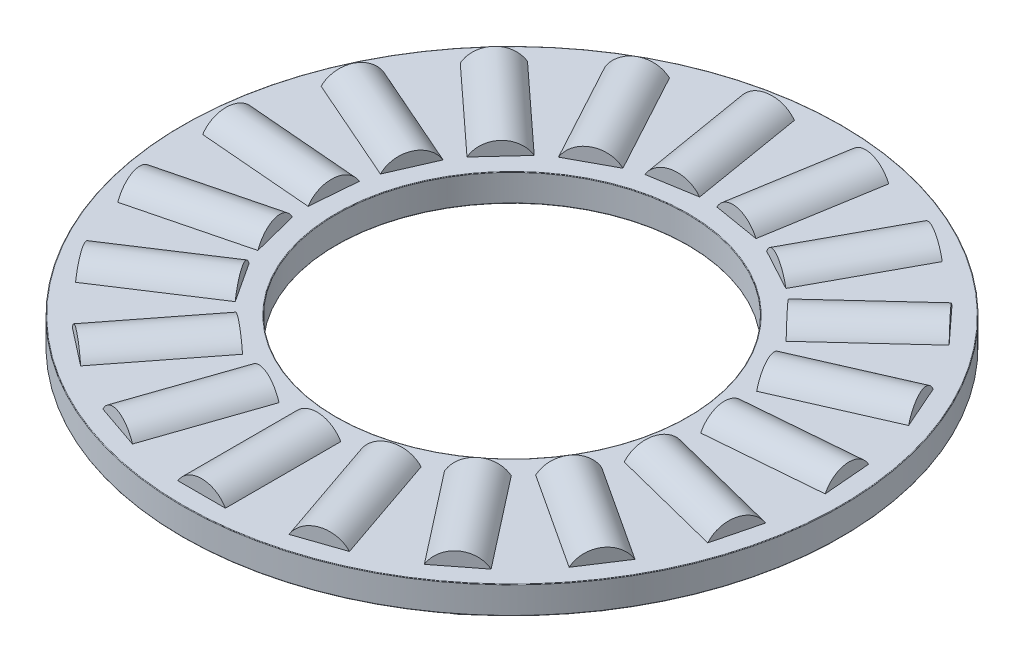
from build123d import *

# Parameters (mm, degrees)
SKETCH1_W         = 5.55625
SKETCH1_H         = 0.9921875
SKETCH3_W         = 4.1671875
SKETCH3_H         = 0.9921875
SKETCH2_W         = 4.1671875
SKETCH2_H         = 0.9921875
CIRPATTERN1_COUNT = 19
CIRPATTERN1_ANGLE = 341.052631579
CIRPATTERN2_COUNT = 19
FILLET2_R         = 0.01984375


with BuildPart() as part:
    # Sketch1 → Revolve1 (revolve)
    with BuildSketch(Plane(origin=(0, 0, 0), x_dir=(0, 0, -1), z_dir=(1, 0, 0)), mode=Mode.PRIVATE) as revolve1_sk:
        with Locations((-9.128125, 0)):
            Rectangle(SKETCH1_W, SKETCH1_H)
    revolve(revolve1_sk.sketch.rotate(Axis((0, -0.9921875, 0), (0, 1, 0)), 180), axis=Axis((0, -0.9921875, 0), (0, 1, 0)))

    # Sketch3 → Cut-Revolve1 (revolve, cut)
    with BuildSketch(Plane(origin=(0, 0, 0), x_dir=(0, 0, -1), z_dir=(1, 0, 0))):
        with Locations((-9.128125, 0.49609375)):
            Rectangle(SKETCH3_W, SKETCH3_H)
    cut_revolve1 = revolve(axis=Axis((0, 0, 11.21171875), (0, 0, -1)), mode=Mode.SUBTRACT)

    # CirPattern2: Cut-Revolve1 ×19 about axis
    cirpattern2_axis = Axis((0, 0, 0), (0, 1, 0))
    for i in range(1, CIRPATTERN2_COUNT):
        add(cut_revolve1.rotate(cirpattern2_axis, i * 360 / CIRPATTERN2_COUNT), mode=Mode.SUBTRACT)

    # Fillet2
    fillet2_edges = [part.edges().sort_by_distance(p)[0] for p in [
        (0, 0.49609375, 11.90625),
        (0, 0.49609375, 6.35),
        (0, -0.49609375, 6.35),
        (0, -0.49609375, 11.90625),
    ]]
    fillet(fillet2_edges, radius=FILLET2_R)


with BuildPart() as body_2:
    # Sketch2 → Revolve2 (revolve)
    with BuildSketch(Plane(origin=(0, 0, 0), x_dir=(0, 0, -1), z_dir=(1, 0, 0)), mode=Mode.PRIVATE) as revolve2_sk:
        with Locations((-9.128125, 0.49609375)):
            Rectangle(SKETCH2_W, SKETCH2_H)
    revolve(revolve2_sk.sketch.rotate(Axis((0, 0, 11.21171875), (0, 0, -1)), 90), axis=Axis((0, 0, 11.21171875), (0, 0, -1)))


with BuildPart() as cirpattern1_1:
    # CirPattern1: pattern copy
    add(body_2.part.rotate(Axis((0, 0.9921875, 0), (0, -1, 0)), 1 * CIRPATTERN1_ANGLE / (CIRPATTERN1_COUNT - 1)))


with BuildPart() as cirpattern1_2:
    # CirPattern1: pattern copy
    add(body_2.part.rotate(Axis((0, 0.9921875, 0), (0, -1, 0)), 2 * CIRPATTERN1_ANGLE / (CIRPATTERN1_COUNT - 1)))


with BuildPart() as cirpattern1_3:
    # CirPattern1: pattern copy
    add(body_2.part.rotate(Axis((0, 0.9921875, 0), (0, -1, 0)), 3 * CIRPATTERN1_ANGLE / (CIRPATTERN1_COUNT - 1)))


with BuildPart() as cirpattern1_4:
    # CirPattern1: pattern copy
    add(body_2.part.rotate(Axis((0, 0.9921875, 0), (0, -1, 0)), 4 * CIRPATTERN1_ANGLE / (CIRPATTERN1_COUNT - 1)))


with BuildPart() as cirpattern1_5:
    # CirPattern1: pattern copy
    add(body_2.part.rotate(Axis((0, 0.9921875, 0), (0, -1, 0)), 5 * CIRPATTERN1_ANGLE / (CIRPATTERN1_COUNT - 1)))


with BuildPart() as cirpattern1_6:
    # CirPattern1: pattern copy
    add(body_2.part.rotate(Axis((0, 0.9921875, 0), (0, -1, 0)), 6 * CIRPATTERN1_ANGLE / (CIRPATTERN1_COUNT - 1)))


with BuildPart() as cirpattern1_7:
    # CirPattern1: pattern copy
    add(body_2.part.rotate(Axis((0, 0.9921875, 0), (0, -1, 0)), 7 * CIRPATTERN1_ANGLE / (CIRPATTERN1_COUNT - 1)))


with BuildPart() as cirpattern1_8:
    # CirPattern1: pattern copy
    add(body_2.part.rotate(Axis((0, 0.9921875, 0), (0, -1, 0)), 8 * CIRPATTERN1_ANGLE / (CIRPATTERN1_COUNT - 1)))


with BuildPart() as cirpattern1_9:
    # CirPattern1: pattern copy
    add(body_2.part.rotate(Axis((0, 0.9921875, 0), (0, -1, 0)), 9 * CIRPATTERN1_ANGLE / (CIRPATTERN1_COUNT - 1)))


with BuildPart() as cirpattern1_10:
    # CirPattern1: pattern copy
    add(body_2.part.rotate(Axis((0, 0.9921875, 0), (0, -1, 0)), 10 * CIRPATTERN1_ANGLE / (CIRPATTERN1_COUNT - 1)))


with BuildPart() as cirpattern1_11:
    # CirPattern1: pattern copy
    add(body_2.part.rotate(Axis((0, 0.9921875, 0), (0, -1, 0)), 11 * CIRPATTERN1_ANGLE / (CIRPATTERN1_COUNT - 1)))


with BuildPart() as cirpattern1_12:
    # CirPattern1: pattern copy
    add(body_2.part.rotate(Axis((0, 0.9921875, 0), (0, -1, 0)), 12 * CIRPATTERN1_ANGLE / (CIRPATTERN1_COUNT - 1)))


with BuildPart() as cirpattern1_13:
    # CirPattern1: pattern copy
    add(body_2.part.rotate(Axis((0, 0.9921875, 0), (0, -1, 0)), 13 * CIRPATTERN1_ANGLE / (CIRPATTERN1_COUNT - 1)))


with BuildPart() as cirpattern1_14:
    # CirPattern1: pattern copy
    add(body_2.part.rotate(Axis((0, 0.9921875, 0), (0, -1, 0)), 14 * CIRPATTERN1_ANGLE / (CIRPATTERN1_COUNT - 1)))


with BuildPart() as cirpattern1_15:
    # CirPattern1: pattern copy
    add(body_2.part.rotate(Axis((0, 0.9921875, 0), (0, -1, 0)), 15 * CIRPATTERN1_ANGLE / (CIRPATTERN1_COUNT - 1)))


with BuildPart() as cirpattern1_16:
    # CirPattern1: pattern copy
    add(body_2.part.rotate(Axis((0, 0.9921875, 0), (0, -1, 0)), 16 * CIRPATTERN1_ANGLE / (CIRPATTERN1_COUNT - 1)))


with BuildPart() as cirpattern1_17:
    # CirPattern1: pattern copy
    add(body_2.part.rotate(Axis((0, 0.9921875, 0), (0, -1, 0)), 17 * CIRPATTERN1_ANGLE / (CIRPATTERN1_COUNT - 1)))


with BuildPart() as cirpattern1_18:
    # CirPattern1: pattern copy
    add(body_2.part.rotate(Axis((0, 0.9921875, 0), (0, -1, 0)), 18 * CIRPATTERN1_ANGLE / (CIRPATTERN1_COUNT - 1)))


solid = Compound([part.part, body_2.part, cirpattern1_1.part, cirpattern1_2.part, cirpattern1_3.part, cirpattern1_4.part, cirpattern1_5.part, cirpattern1_6.part, cirpattern1_7.part, cirpattern1_8.part, cirpattern1_9.part, cirpattern1_10.part, cirpattern1_11.part, cirpattern1_12.part, cirpattern1_13.part, cirpattern1_14.part, cirpattern1_15.part, cirpattern1_16.part, cirpattern1_17.part, cirpattern1_18.part])
